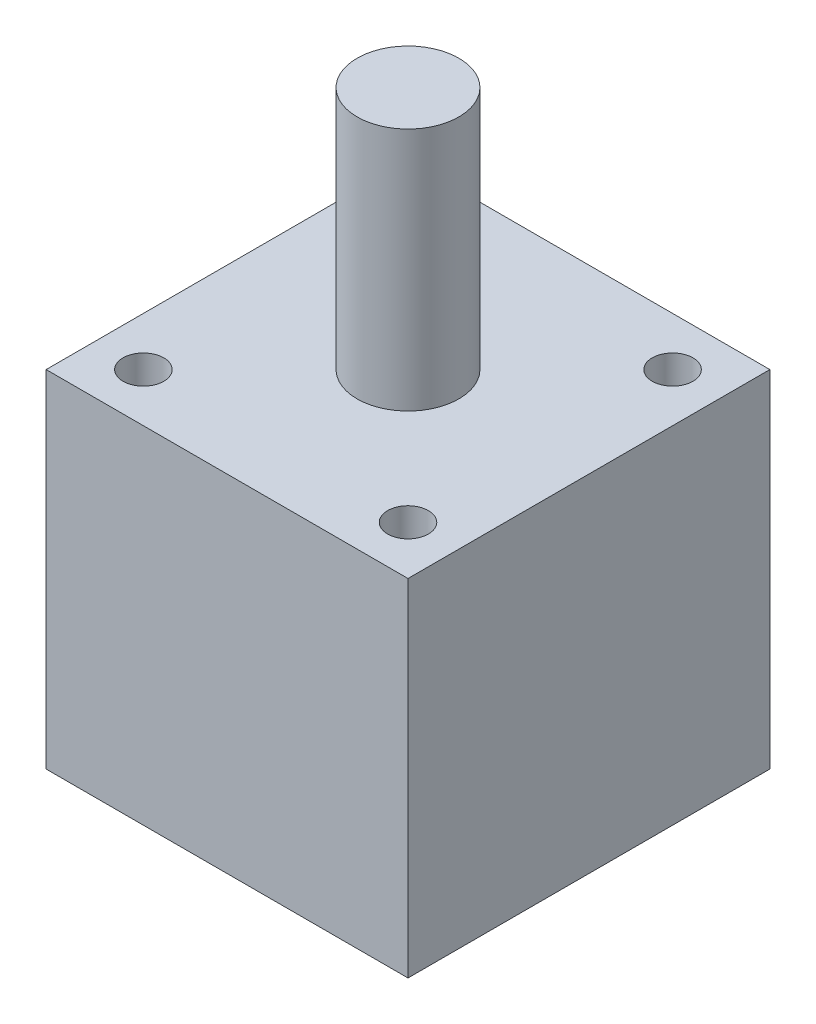
from build123d import *

# Parameters (mm, degrees)
SKETCH1_W           = 35.56
SKETCH1_H           = 35.56
BOSS_EXTRUDE1_DEPTH = 34
SKETCH2_R           = 5
BOSS_EXTRUDE2_DEPTH = 24
SKETCH3_R           = 5
BOSS_EXTRUDE3_DEPTH = 12
SKETCH4_R           = 2
CUT_EXTRUDE1_DEPTH  = 34


with BuildPart() as part:
    # Sketch1 → Boss-Extrude1 (new body)
    with BuildSketch(Plane(origin=(0, 0, 0), x_dir=(1, 0, 0), z_dir=(0, 1, 0))):
        Rectangle(SKETCH1_W, SKETCH1_H)
    extrude(amount=BOSS_EXTRUDE1_DEPTH)

    # Sketch2 → Boss-Extrude2 (add)
    with BuildSketch(Plane(origin=(0, 34, 0), x_dir=(1, 0, 0), z_dir=(0, 1, 0))):
        Circle(SKETCH2_R)
    extrude(amount=BOSS_EXTRUDE2_DEPTH)

    # Sketch3 → Boss-Extrude3 (add)
    with BuildSketch(Plane.XZ):
        Circle(SKETCH3_R)
    extrude(amount=BOSS_EXTRUDE3_DEPTH)

    # Sketch4 → Cut-Extrude1 (cut)
    with BuildSketch(Plane(origin=(0, 34, 0), x_dir=(1, 0, 0), z_dir=(0, 1, 0))):
        with Locations((-13, 13)):
            Circle(SKETCH4_R)
        with Locations((13, 13)):
            Circle(SKETCH4_R)
        with Locations((13, -13)):
            Circle(SKETCH4_R)
        with Locations((-13, -13)):
            Circle(SKETCH4_R)
    extrude(amount=-CUT_EXTRUDE1_DEPTH, mode=Mode.SUBTRACT)


solid = part.part
